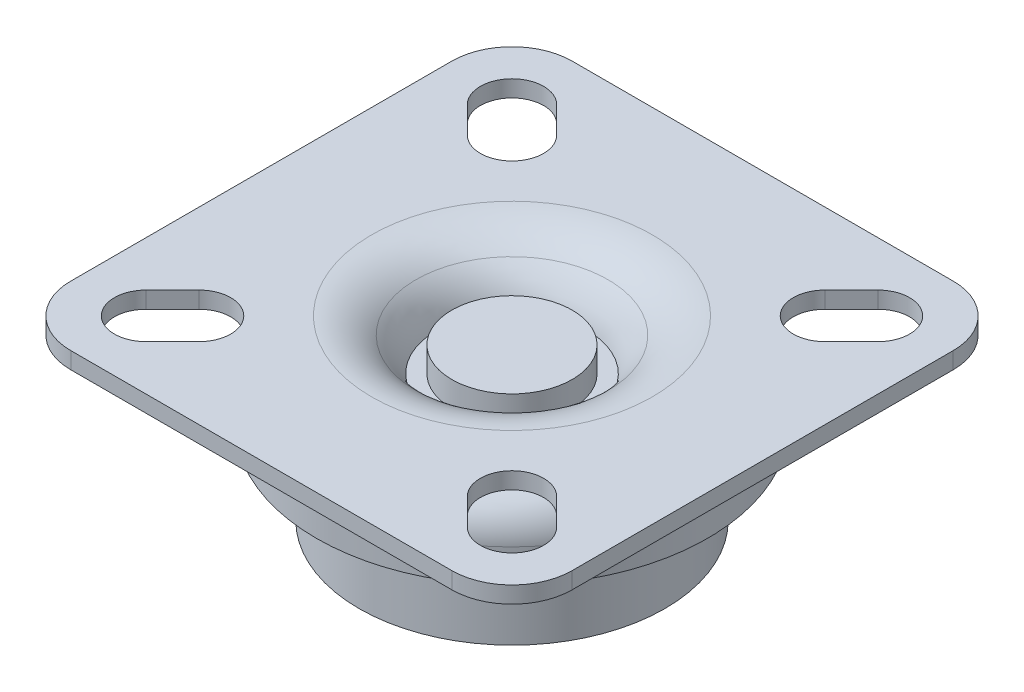
from build123d import *

# Parameters (mm, degrees)
SKETCH1_W              = 50
SKETCH1_H              = 50
BOSS_PLATE_DEPTH       = 1.66
FILLET_PLATE_CORNERS_R = 6
CUT_SLOT_DEPTH         = 36.394287675
SLOT_PATTERN_COUNT     = 4
FILLET2_R              = 4.5


with BuildPart() as part:
    # Sketch1 → boss_plate (new body)
    with BuildSketch(Plane(origin=(0, 0, 0), x_dir=(1, 0, 0), z_dir=(0, 1, 0))):
        Rectangle(SKETCH1_W, SKETCH1_H)
    extrude(amount=BOSS_PLATE_DEPTH)

    # fillet plate corners
    fillet_plate_corners_edges = [part.edges().sort_by_distance(p)[0] for p in [
        (25, 0.83, 25),
        (-25, 0.83, -25),
        (25, 0.83, -25),
        (-25, 0.83, 25),
    ]]
    fillet(fillet_plate_corners_edges, radius=FILLET_PLATE_CORNERS_R)

    # Sketch2 → cut slot (cut, through all)
    with BuildSketch(Plane(origin=(0, 1.66, 0), x_dir=(1, 0, 0), z_dir=(0, 1, 0))):
        with BuildLine():
            Line((13.372613639, 17.827386361), (16.022613639, 20.477386361))
            ThreePointArc((16.022613639, 20.477386361), (20.477386361, 20.477386361), (20.477386361, 16.022613639))
            Line((20.477386361, 16.022613639), (17.827386361, 13.372613639))
            ThreePointArc((17.827386361, 13.372613639), (13.372613639, 13.372613639), (13.372613639, 17.827386361))
        make_face()
    cut_slot = extrude(amount=-CUT_SLOT_DEPTH, mode=Mode.SUBTRACT)

    # slot pattern: cut slot ×4 about axis
    slot_pattern_axis = Axis((0, -2.147420323, 0), (0, 1, 0))
    for i in range(1, SLOT_PATTERN_COUNT):
        add(cut_slot.rotate(slot_pattern_axis, i * 360 / SLOT_PATTERN_COUNT), mode=Mode.SUBTRACT)


with BuildPart() as body_2:
    # Sketch3 → bearing_upper_seat (revolve)
    with BuildSketch(Plane.XY):
        with BuildLine():
            Line((19.51, -7.8), (19.51, 0))
            Line((19.51, 0), (0, 0))
            Line((0, 0), (0, -10.7))
            Line((0, -10.7), (4.5, -10.7))
            ThreePointArc((4.5, -10.7), (9.873837084, -12.1171459), (13.85, -16))
            Line((13.85, -16), (15.25, -16))
            Line((15.25, -16), (15.25, -7.8))
            Line((15.25, -7.8), (19.51, -7.8))
        make_face()
    revolve(axis=Axis((0, 0, 0), (0, -1, 0)))


with BuildPart() as cut_plate_forming_tool:
    # Sketch4 → cut_plate_forming (revolve)
    with BuildSketch(Plane.XY):
        with BuildLine():
            Line((-6, -3.34), (-6, -0.84))
            Line((-6, -0.84), (0, -0.84))
            Line((0, -0.84), (0, 1.66))
            Line((0, 1.66), (-14, 1.66))
            ThreePointArc((-14, 1.66), (-9.899695133, 0.265396327), (-7.5, -3.34))
            Line((-7.5, -3.34), (-6, -3.34))
        make_face()
    revolve(axis=Axis((0, 1.66, 0), (0, -1, 0)))


with BuildPart() as part_1:
    add(part.part)

    # cut_plate_forming: cut by cut_plate_forming_tool
    add(cut_plate_forming_tool.part, mode=Mode.SUBTRACT)


with BuildPart() as body_2_1:
    add(body_2.part)

    # cut_plate_forming: cut by cut_plate_forming_tool
    add(cut_plate_forming_tool.part, mode=Mode.SUBTRACT)

    # Fillet2
    fillet2_edges = [body_2_1.edges().sort_by_distance(p)[0] for p in [
        (-19.51, 0, 0),
    ]]
    fillet(fillet2_edges, radius=FILLET2_R)


solid = Compound([part_1.part, body_2_1.part])
